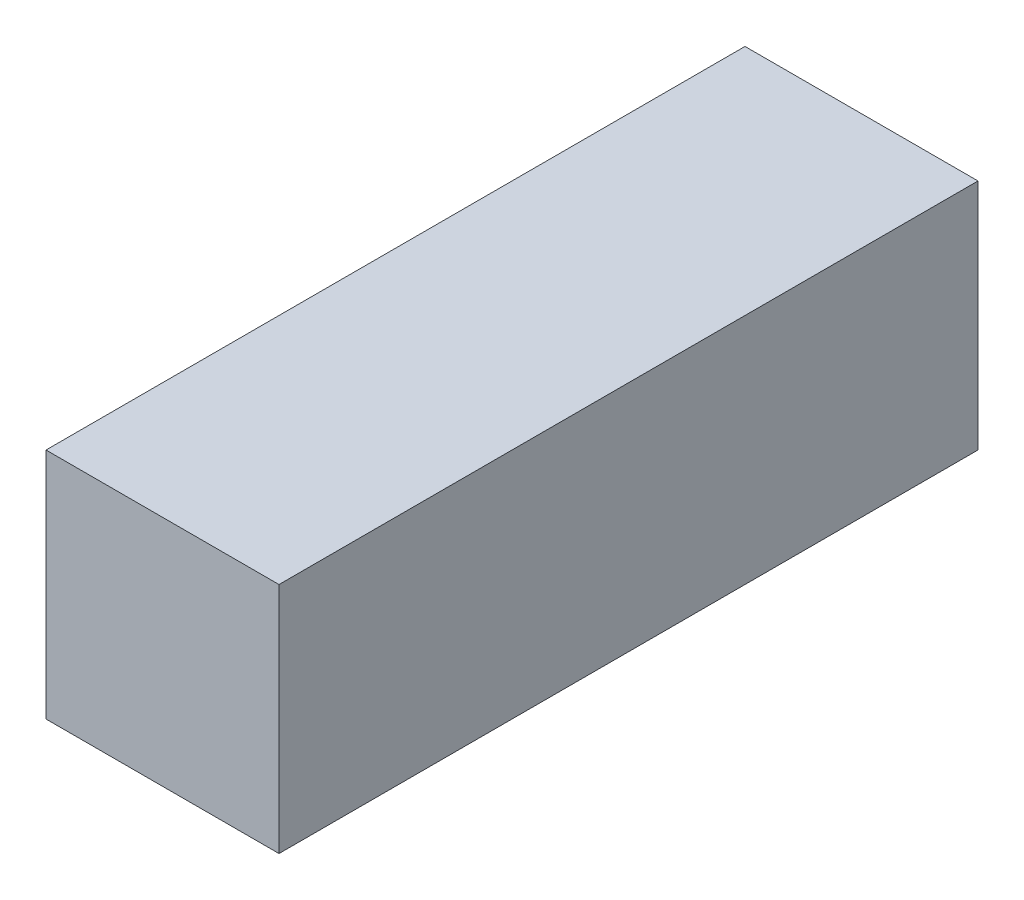
from build123d import *

# Parameters (mm, degrees)
SKETCH1_W           = 6.35
SKETCH1_H           = 6.35
BOSS_EXTRUDE1_DEPTH = 19.05


with BuildPart() as part:
    # Sketch1 → Boss-Extrude1 (new body)
    with BuildSketch(Plane.XY):
        Rectangle(SKETCH1_W, SKETCH1_H)
    extrude(amount=BOSS_EXTRUDE1_DEPTH)


solid = part.part
